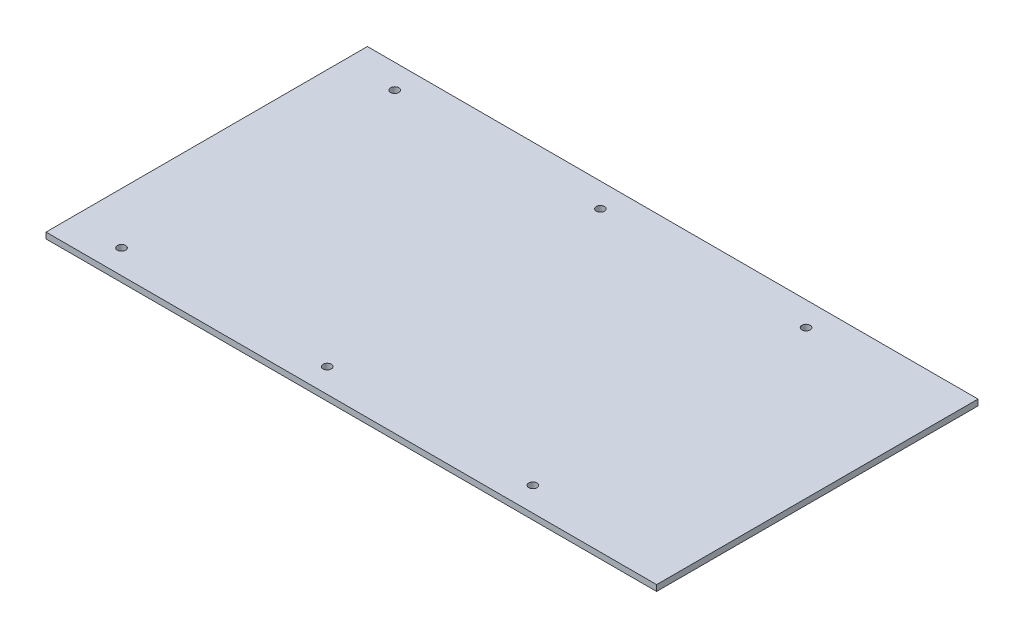
from build123d import *

# Parameters (mm, degrees)
SKETCH1_W                 = 203.2
SKETCH1_H                 = 127
EXTRUDE1_DEPTH            = 2.3622
F_4_CLEARANCE_HOLE1_D     = 3.2639
F_4_CLEARANCE_HOLE1_DEPTH = 6.35
F_4_CLEARANCE_HOLE1_TIP   = 0.980574487
SKETCH3_W                 = 38.1
SKETCH3_H                 = 127
EXTRUDE2_DEPTH            = 2.3622


with BuildPart() as part:
    # Sketch1 → Extrude1 (new body)
    with BuildSketch(Plane(origin=(0, 0, 0), x_dir=(1, 0, 0), z_dir=(0, 1, 0))):
        Rectangle(SKETCH1_W, SKETCH1_H)
    extrude(amount=EXTRUDE1_DEPTH)

    # #4 Clearance Hole1
    with Locations(Plane(origin=(-81.28, 2.3622, -53.975), x_dir=(0, 0, 1), z_dir=(0, 1, 0))):
        with Locations((0, 0), (0, 81.28), (107.95, 81.28), (107.95, 0), (107.95, 162.56), (0, 162.56)):
            Hole(F_4_CLEARANCE_HOLE1_D / 2, depth=F_4_CLEARANCE_HOLE1_DEPTH)
            with Locations((0, 0, -(F_4_CLEARANCE_HOLE1_DEPTH + F_4_CLEARANCE_HOLE1_TIP / 2))):  # 118° drill point
                Cone(0, F_4_CLEARANCE_HOLE1_D / 2, F_4_CLEARANCE_HOLE1_TIP, mode=Mode.SUBTRACT)

    # Sketch3 → Extrude2 (add)
    with BuildSketch(Plane(origin=(0, 0, 0), x_dir=(1, 0, 0), z_dir=(0, 1, 0))):
        with Locations((120.65, 0)):
            Rectangle(SKETCH3_W, SKETCH3_H)
    extrude(amount=EXTRUDE2_DEPTH)


solid = part.part
